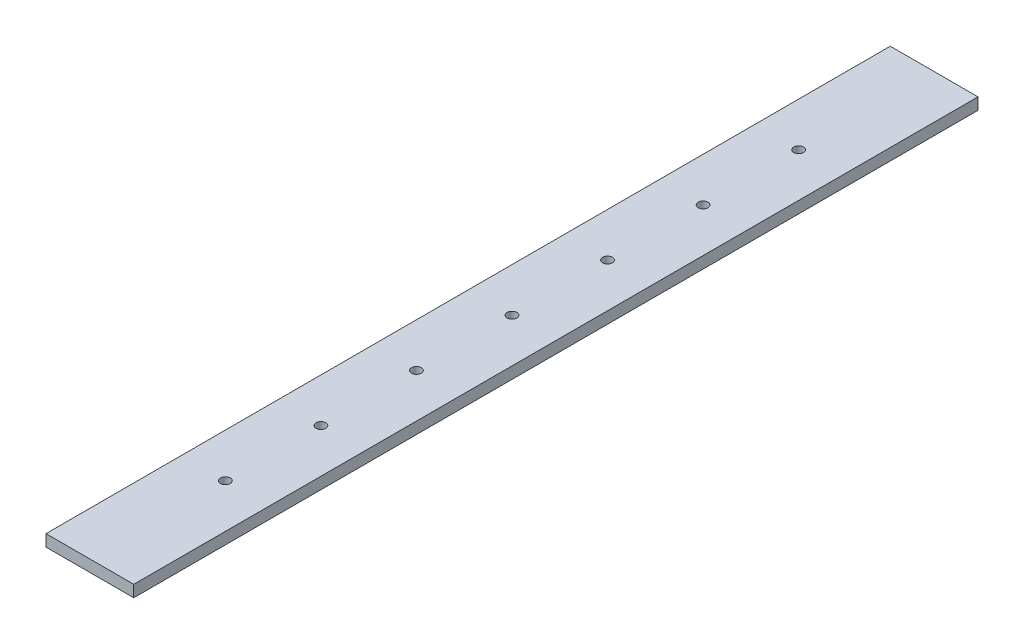
from build123d import *

# Parameters (mm, degrees)
SKETCH1_W           = 285.75
SKETCH1_H           = 2749.55
BOSS_EXTRUDE1_DEPTH = 38.1
SKETCH3_R           = 15.875
CUT_EXTRUDE1_DEPTH  = 39.1


with BuildPart() as part:
    # Sketch1 → Boss-Extrude1 (new body)
    with BuildSketch(Plane(origin=(0, 0, 0), x_dir=(1, 0, 0), z_dir=(0, 1, 0))):
        with Locations((142.875, -1374.775)):
            Rectangle(SKETCH1_W, SKETCH1_H)
    extrude(amount=BOSS_EXTRUDE1_DEPTH)

    # Sketch3 → Cut-Extrude1 (cut, through all)
    with BuildSketch(Plane(origin=(0, 38.1, 0), x_dir=(1, 0, 0), z_dir=(0, 1, 0))):
        with Locations((142.875, -2308.225)):
            Circle(SKETCH3_R)
        with Locations((142.875, -1997.075)):
            Circle(SKETCH3_R)
        with Locations((142.875, -1685.925)):
            Circle(SKETCH3_R)
        with Locations((142.875, -1374.775)):
            Circle(SKETCH3_R)
        with Locations((142.875, -1063.625)):
            Circle(SKETCH3_R)
        with Locations((142.875, -752.475)):
            Circle(SKETCH3_R)
        with Locations((142.875, -441.325)):
            Circle(SKETCH3_R)
    extrude(amount=-CUT_EXTRUDE1_DEPTH, mode=Mode.SUBTRACT)


solid = part.part
